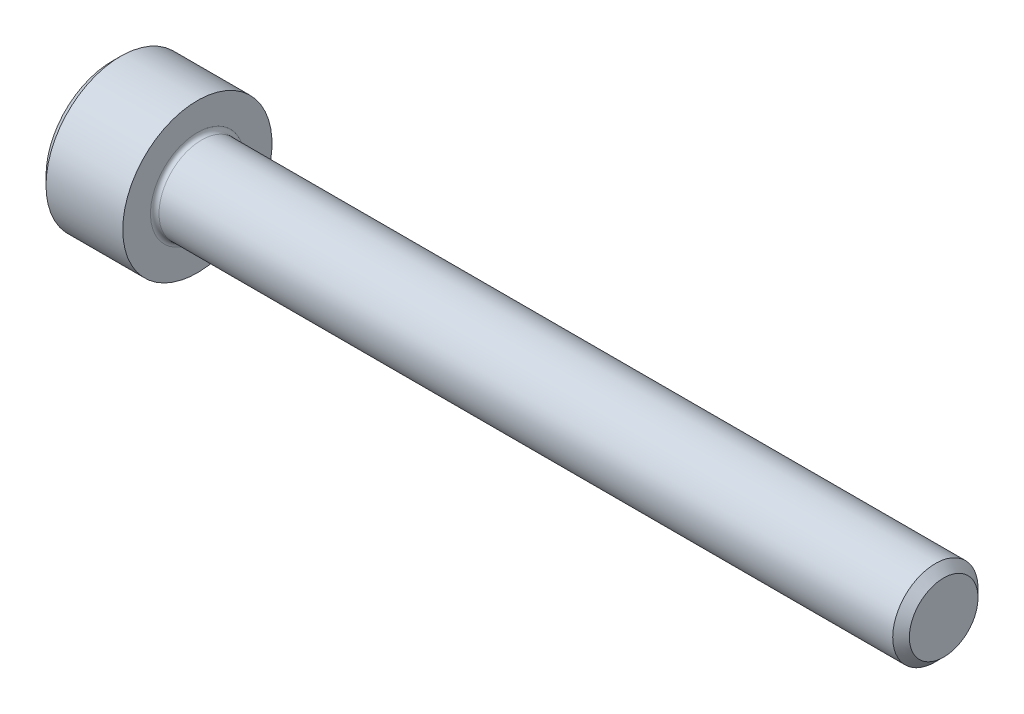
from build123d import *

# Parameters (mm, degrees)
FILLET1_R   = 0.2
HEX_2_DEPTH = 2


with BuildPart() as part:
    # BodySke → Base-Revolve (revolve)
    with BuildSketch(Plane.XY):
        Polygon((0, 0), (0, 3.1), (0.4, 3.5), (4, 3.5), (4, 2), (38.61, 2), (39, 1.61), (39, 0), align=None)
    revolve(axis=Axis((-31.75, 0, 0), (1, 0, 0)))

    # Fillet1
    fillet1_edges = [part.edges().sort_by_distance(p)[0] for p in [
        (4, -2, 0),
    ]]
    fillet(fillet1_edges, radius=FILLET1_R)

    # Sketch2 → Hex-PreBroach (revolve, cut)
    with BuildSketch(Plane.XY):
        Polygon((0, 1.5355), (2, 1.5355), (2.886521338, 0), (0, 0), align=None)
    revolve(axis=Axis((0, 0, 0), (1, 0, 0)), mode=Mode.SUBTRACT)

    # Sketch3 → Hex 2 (cut)
    with BuildSketch(Plane(origin=(0, 0, 0), x_dir=(0, 0.5, 0.866025404), z_dir=(-1, 0, 0))):
        Polygon((0.886521338, 1.5355), (-0.886521338, 1.5355), (-1.773042677, 0), (-0.886521338, -1.5355), (0.886521338, -1.5355), (1.773042677, 0), align=None)
    extrude(amount=-HEX_2_DEPTH, mode=Mode.SUBTRACT)


solid = part.part
